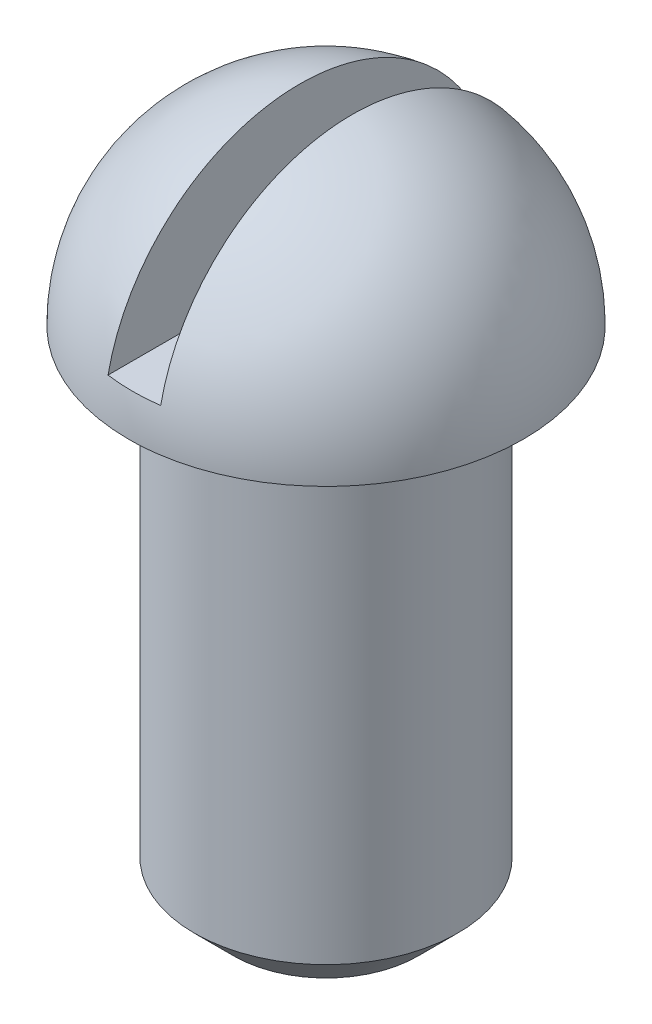
from build123d import *

# Parameters (mm, degrees)
SKETCH2_R               = 10
BOSS_EXTRUDE1_DEPTH     = 38
SKETCH4_W               = 4
SKETCH4_H               = 16.517828645
CUT_EXTRUDE1_DEPTH      = 16
CUT_EXTRUDE1_DEPTH_BACK = 16
CHAMFER1_SIZE           = 3


with BuildPart() as part:
    # Sketch2 → Boss-Extrude1 (new body)
    with BuildSketch(Plane(origin=(0, 0, 0), x_dir=(1, 0, 0), z_dir=(0, 1, 0))):
        Circle(SKETCH2_R)
    extrude(amount=BOSS_EXTRUDE1_DEPTH)

    # Sketch3 → Revolve2 (revolve)
    with BuildSketch(Plane.XY):
        with BuildLine():
            Line((0, 53), (0, 38))
            Line((0, 38), (-15, 38))
            ThreePointArc((-15, 38), (-10.606601718, 48.606601718), (0, 53))
        make_face()
    revolve(axis=Axis((0, 67.240353694, 0), (0, -1, 0)))

    # Sketch4 → Cut-Extrude1 (cut, two sides)
    with BuildSketch(Plane.XY) as cut_extrude1_sk:
        with Locations((0, 49.258914323)):
            Rectangle(SKETCH4_W, SKETCH4_H)
    extrude(amount=CUT_EXTRUDE1_DEPTH, mode=Mode.SUBTRACT)
    extrude(cut_extrude1_sk.sketch, amount=-CUT_EXTRUDE1_DEPTH_BACK, mode=Mode.SUBTRACT)

    # Chamfer1
    chamfer1_edges = [part.edges().sort_by_distance(p)[0] for p in [
        (-10, 0, 0),
    ]]
    chamfer(chamfer1_edges, length=CHAMFER1_SIZE)


solid = part.part
